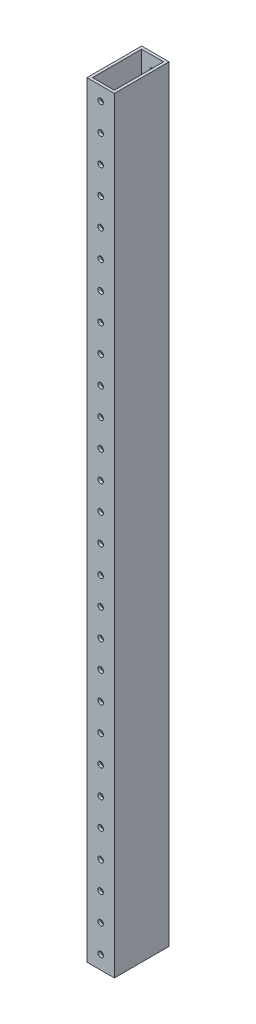
from build123d import *

# Parameters (mm, degrees)
SKETCH1_W               = 25.4
SKETCH1_H               = 50.8
SKETCH1_W_2             = 20.32
SKETCH1_H_2             = 45.72
BOSS_EXTRUDE2_DEPTH     = 711.2
SKETCH3_R               = 2.54
CUT_EXTRUDE1_DEPTH      = 1
CUT_EXTRUDE1_DEPTH_BACK = 51.8


with BuildPart() as part:
    # Sketch1 → Boss-Extrude2 (new body)
    with BuildSketch(Plane(origin=(0, 0, 0), x_dir=(1, 0, 0), z_dir=(0, 1, 0))):
        with Locations((-36.061676357, 9.915431316)):
            Rectangle(SKETCH1_W, SKETCH1_H)
        with Locations((-36.061676357, 9.915431316)):
            Rectangle(SKETCH1_W_2, SKETCH1_H_2, mode=Mode.SUBTRACT)
    extrude(amount=BOSS_EXTRUDE2_DEPTH)

    # Sketch3 → Cut-Extrude1 (cut, two sides)
    with BuildSketch(Plane.XY.offset(15.484568684)) as cut_extrude1_sk:
        with Locations((-36.061676357, 12.7)):
            Circle(SKETCH3_R)
        with Locations((-36.061676357, 38.1)):
            Circle(SKETCH3_R)
        with Locations((-36.061676357, 63.5)):
            Circle(SKETCH3_R)
        with Locations((-36.061676357, 88.9)):
            Circle(SKETCH3_R)
        with Locations((-36.061676357, 114.3)):
            Circle(SKETCH3_R)
        with Locations((-36.061676357, 139.7)):
            Circle(SKETCH3_R)
        with Locations((-36.061676357, 165.1)):
            Circle(SKETCH3_R)
        with Locations((-36.061676357, 190.5)):
            Circle(SKETCH3_R)
        with Locations((-36.061676357, 215.9)):
            Circle(SKETCH3_R)
        with Locations((-36.061676357, 241.3)):
            Circle(SKETCH3_R)
        with Locations((-36.061676357, 266.7)):
            Circle(SKETCH3_R)
        with Locations((-36.061676357, 292.1)):
            Circle(SKETCH3_R)
        with Locations((-36.061676357, 317.5)):
            Circle(SKETCH3_R)
        with Locations((-36.061676357, 342.9)):
            Circle(SKETCH3_R)
        with Locations((-36.061676357, 368.3)):
            Circle(SKETCH3_R)
        with Locations((-36.061676357, 393.7)):
            Circle(SKETCH3_R)
        with Locations((-36.061676357, 419.1)):
            Circle(SKETCH3_R)
        with Locations((-36.061676357, 444.5)):
            Circle(SKETCH3_R)
        with Locations((-36.061676357, 469.9)):
            Circle(SKETCH3_R)
        with Locations((-36.061676357, 495.3)):
            Circle(SKETCH3_R)
        with Locations((-36.061676357, 520.7)):
            Circle(SKETCH3_R)
        with Locations((-36.061676357, 546.1)):
            Circle(SKETCH3_R)
        with Locations((-36.061676357, 571.5)):
            Circle(SKETCH3_R)
        with Locations((-36.061676357, 596.9)):
            Circle(SKETCH3_R)
        with Locations((-36.061676357, 622.3)):
            Circle(SKETCH3_R)
        with Locations((-36.061676357, 647.7)):
            Circle(SKETCH3_R)
        with Locations((-36.061676357, 673.1)):
            Circle(SKETCH3_R)
        with Locations((-36.061676357, 698.5)):
            Circle(SKETCH3_R)
    extrude(amount=CUT_EXTRUDE1_DEPTH, mode=Mode.SUBTRACT)
    extrude(cut_extrude1_sk.sketch, amount=-CUT_EXTRUDE1_DEPTH_BACK, mode=Mode.SUBTRACT)


solid = part.part
